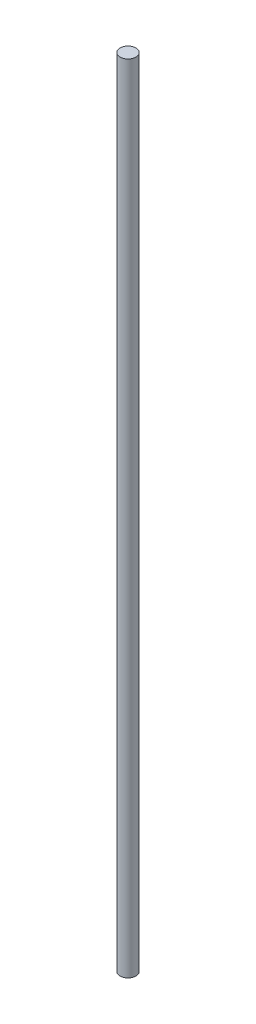
from build123d import *

# Parameters (mm, degrees)
SKETCH1_R           = 5
BOSS_EXTRUDE1_DEPTH = 500


with BuildPart() as part:
    # Sketch1 → Boss-Extrude1 (new body)
    with BuildSketch(Plane(origin=(0, 0, 0), x_dir=(1, 0, 0), z_dir=(0, 1, 0))):
        with Locations(Location((0, 0, 0), (0, 0, 270))):  # turned: the seam where the file's is
            Circle(SKETCH1_R)
    extrude(amount=BOSS_EXTRUDE1_DEPTH)


solid = part.part
